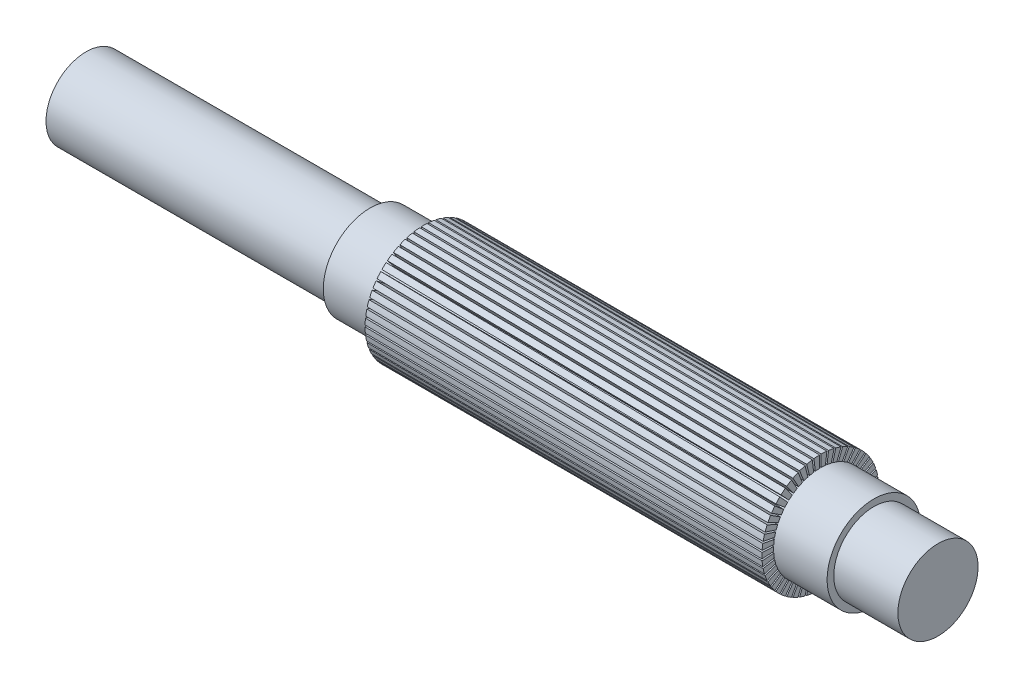
from build123d import *

# Parameters (mm, degrees)
CIRPATTERN1_COUNT = 50


with BuildPart() as part:
    # Sketch2 → Revolve3 (revolve)
    with BuildSketch(Plane.XY):
        Polygon((-127.5, 0), (-127.5, 12), (-42.5, 12), (-42.5, 14), (-26.5, 14), (-26.5, 17.5), (92.3, 17.5), (92.3, 14), (108.3, 14), (108.3, 12), (127.5, 12), (127.5, 0), align=None)
    revolve(axis=Axis((-127.5, 0, 0), (1, 0, 0)))

    # Sketch3 → Cut-Loft1 section 0
    with BuildSketch(Plane(origin=(92.3, 0, 0), x_dir=(0, 0, -1), z_dir=(1, 0, 0))):
        with BuildLine():
            Line((-0.25, 17.997767679), (-0.25, 13.997767679))
            ThreePointArc((-0.25, 13.997767679), (0, 14), (0.25, 13.997767679))
            Line((0.25, 13.997767679), (0.25, 17.997767679))
            Line((0.25, 17.997767679), (-0.25, 17.997767679))
        make_face()
    # Sketch4 → Cut-Loft1 section 1
    with BuildSketch(Plane.ZY.offset(26.5)):
        with BuildLine():
            Line((-1.220180398, 13.946725773), (-1.525225498, 17.433407217))
            ThreePointArc((-1.525225498, 17.433407217), (-1.275995726, 17.453419003), (-1.026505481, 17.469867959))
            Line((-1.026505481, 17.469867959), (-0.721304625, 13.981406211))
            ThreePointArc((-0.721304625, 13.981406211), (-0.970897372, 13.966293649), (-1.220180398, 13.946725773))
        make_face()
    cut_loft1 = loft(mode=Mode.SUBTRACT)

    # CirPattern1: Cut-Loft1 ×50 about axis
    cirpattern1_axis = Axis((-127.5, 0, 0), (-1, 0, 0))
    for i in range(1, CIRPATTERN1_COUNT):
        add(cut_loft1.rotate(cirpattern1_axis, i * 360 / CIRPATTERN1_COUNT), mode=Mode.SUBTRACT)


solid = part.part
